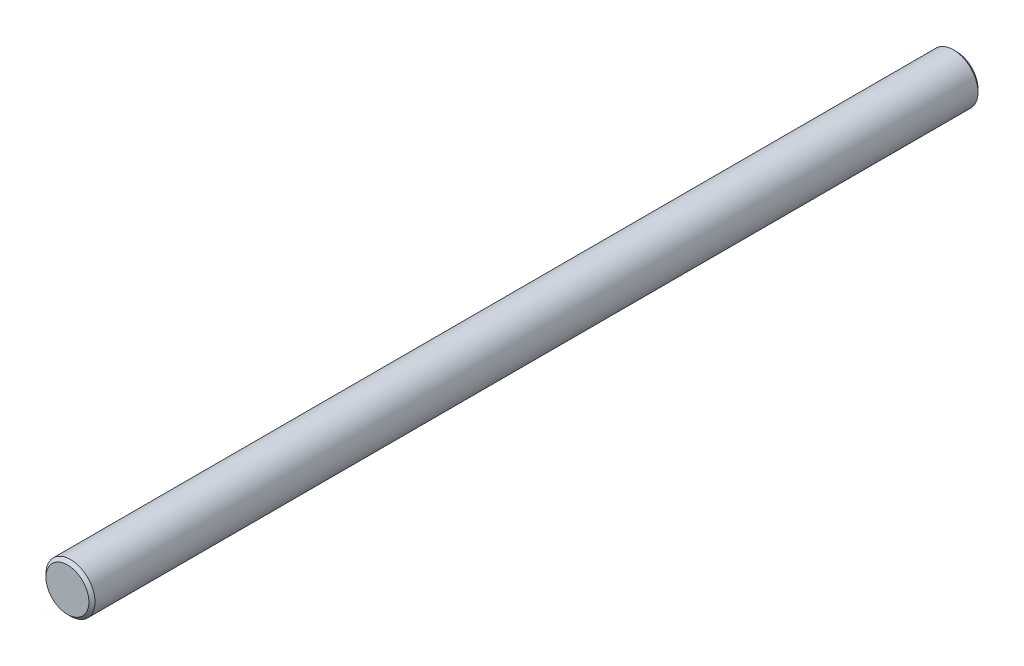
from build123d import *

# Parameters (mm, degrees)
SKETCH2_R           = 4
BOSS_EXTRUDE1_DEPTH = 145
CHAMFER1_SIZE       = 0.5


with BuildPart() as part:
    # Sketch2 → Boss-Extrude1 (new body)
    with BuildSketch(Plane.XY):
        Circle(SKETCH2_R)
    extrude(amount=BOSS_EXTRUDE1_DEPTH)

    # Chamfer1
    chamfer1_edges = [part.edges().sort_by_distance(p)[0] for p in [
        (-4, 0, 0),
        (-4, 0, 145),
    ]]
    chamfer(chamfer1_edges, length=CHAMFER1_SIZE)


solid = part.part
